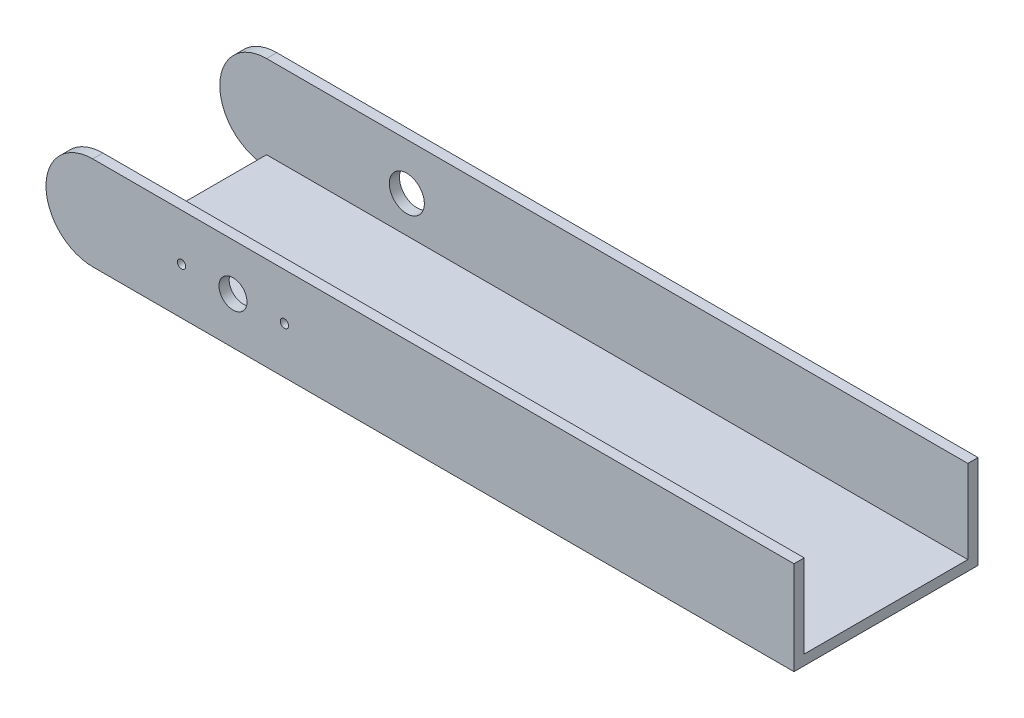
from build123d import *

# Parameters (mm, degrees)
BOSS_EXTRUDE1_DEPTH = 2.7686
SKETCH3_R           = 3.81
SKETCH3_R_2         = 1.1303
CUT_EXTRUDE1_DEPTH  = 3.7686
BOSS_EXTRUDE2_START = -2.7686
SKETCH5_W           = 190.5
SKETCH5_H           = 2.7686
BOSS_EXTRUDE2_DEPTH = 44.45
BOSS_EXTRUDE3_DEPTH = 2.7686
SKETCH7_R           = 4.7625
CUT_EXTRUDE2_DEPTH  = 2.7686


with BuildPart() as part:
    # Sketch1 → Boss-Extrude1 (new body)
    with BuildSketch(Plane.XY):
        with BuildLine():
            Line((0, 0), (190.499997766, 0))
            Line((190.499997766, 0), (190.499997766, 25.4))
            Line((190.499997766, 25.4), (-4.468e-06, 25.4))
            ThreePointArc((-4.468e-06, 25.4), (-12.700002234, 12.699997766), (0, 0))
        make_face()
    extrude(amount=BOSS_EXTRUDE1_DEPTH)

    # Sketch3 → Cut-Extrude1 (cut, through all)
    with BuildSketch(Plane.XY.offset(2.7686)):
        with Locations((38.099997766, 12.7)):
            Circle(SKETCH3_R)
        with Locations((24.129997766, 12.7)):
            Circle(SKETCH3_R_2)
        with Locations((52.069997766, 12.7)):
            Circle(SKETCH3_R_2)
    extrude(amount=-CUT_EXTRUDE1_DEPTH, mode=Mode.SUBTRACT)

    # Sketch5 → Boss-Extrude2 (add)
    with BuildSketch(Plane.XY.offset(2.7686).offset(BOSS_EXTRUDE2_START)):
        with Locations((95.249997766, 1.3843)):
            Rectangle(SKETCH5_W, SKETCH5_H)
    extrude(amount=-BOSS_EXTRUDE2_DEPTH)

    # Sketch6 → Boss-Extrude3 (add)
    with BuildSketch(Plane(origin=(0, 0, -44.45), x_dir=(-1, 0, 0), z_dir=(0, 0, -1))):
        with BuildLine():
            Line((4.468e-06, 25.4), (-190.499997766, 25.4))
            Line((-190.499997766, 25.4), (-190.499997766, 12.7))
            Line((-190.499997766, 12.7), (-190.499997766, 0))
            Line((-190.499997766, 0), (0, 0))
            ThreePointArc((0, 0), (12.700002234, 12.699997766), (4.468e-06, 25.4))
        make_face()
    extrude(amount=BOSS_EXTRUDE3_DEPTH)

    # Sketch7 → Cut-Extrude2 (cut)
    with BuildSketch(Plane(origin=(0, 0, -47.2186), x_dir=(-1, 0, 0), z_dir=(0, 0, -1))):
        with Locations((-38.099997766, 12.7)):
            Circle(SKETCH7_R)
    extrude(amount=-CUT_EXTRUDE2_DEPTH, mode=Mode.SUBTRACT)


solid = part.part
